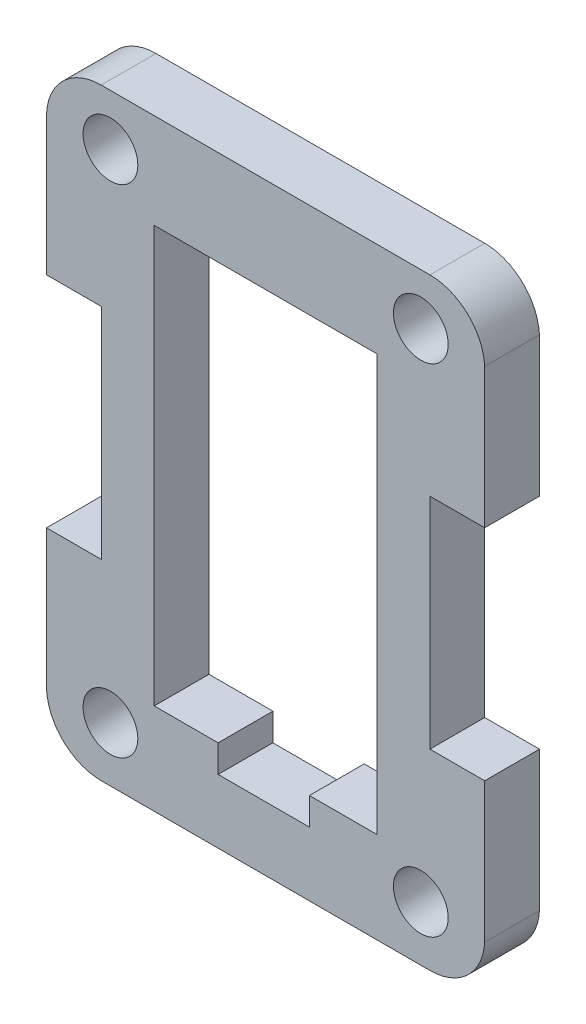
from build123d import *

# Parameters (mm, degrees)
MODEL_R             = 1.5
MODEL_R_2           = 1.500000002
MODEL_R_3           = 1.500000008
BOSS_EXTRUDE1_DEPTH = 3


with BuildPart() as part:
    # Model → Boss-Extrude1 (new body)
    with BuildSketch(Plane.XY):
        with BuildLine():
            Line((41.999920867, 34), (41.999920867, 26.34355613))
            ThreePointArc((41.999920867, 26.34355613), (42.930559932, 24.324015901), (44.9959, 23.5))
            Line((44.9959, 23.5), (62.9999, 23.5))
            ThreePointArc((62.9999, 23.5), (65.067553671, 24.322356447), (65.9999, 26.3428))
            Line((65.9999, 26.3428), (65.9999, 34))
            Line((65.9999, 34), (62.9999, 34))
            Line((62.9999, 34), (62.9999, 46))
            Line((62.9999, 46), (65.9999, 46))
            Line((65.9999, 46), (65.9999, 53.6572))
            ThreePointArc((65.9999, 53.6572), (65.068322251, 55.676912854), (63.002020078, 56.5))
            Line((63.002020078, 56.5), (44.993779922, 56.5))
            ThreePointArc((44.993779922, 56.5), (42.930289539, 55.675803247), (41.999920867, 53.65795613))
            Line((41.999920867, 53.65795613), (41.999920867, 46))
            Line((41.999920867, 46), (44.999920867, 46))
            Line((44.999920867, 46), (44.999920867, 34))
            Line((44.999920867, 34), (41.999920867, 34))
        make_face()
        with Locations((45.4999, 53.700050007)):
            Circle(MODEL_R, mode=Mode.SUBTRACT)
        with Locations((62.4999, 53.700099998)):
            Circle(MODEL_R_2, mode=Mode.SUBTRACT)
        with Locations((45.4999, 26.500000005)):
            Circle(MODEL_R_3, mode=Mode.SUBTRACT)
        with Locations((62.4999, 26.500049996)):
            Circle(MODEL_R, mode=Mode.SUBTRACT)
        Polygon((47.8979, 51.3), (47.8979, 28.5), (51.3979, 28.5), (51.3979, 27), (56.3979, 27), (56.3979, 28.5), (60.0979, 28.5), (60.0979, 51.3), align=None, mode=Mode.SUBTRACT)
    extrude(amount=BOSS_EXTRUDE1_DEPTH)


solid = part.part
